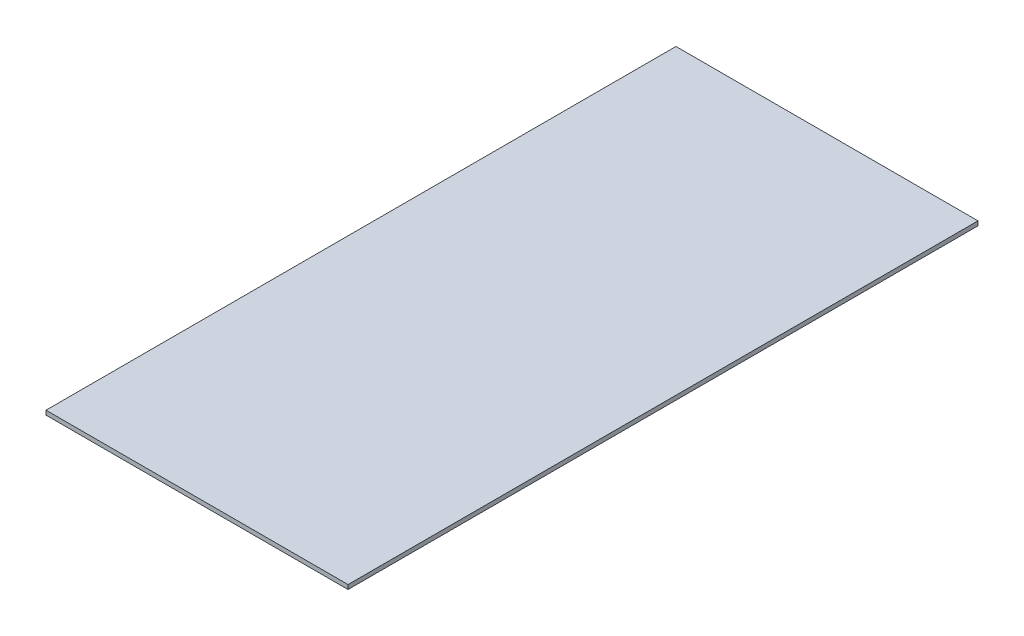
from build123d import *

# Parameters (mm, degrees)
SKETCH1_W           = 177.8
SKETCH1_H           = 370.84
BOSS_EXTRUDE1_DEPTH = 2.54


with BuildPart() as part:
    # Sketch1 → Boss-Extrude1 (new body)
    with BuildSketch(Plane(origin=(0, 0, 0), x_dir=(1, 0, 0), z_dir=(0, 1, 0))):
        with Locations((-103.056050955, -96.803121019)):
            Rectangle(SKETCH1_W, SKETCH1_H)
    extrude(amount=BOSS_EXTRUDE1_DEPTH)


solid = part.part
